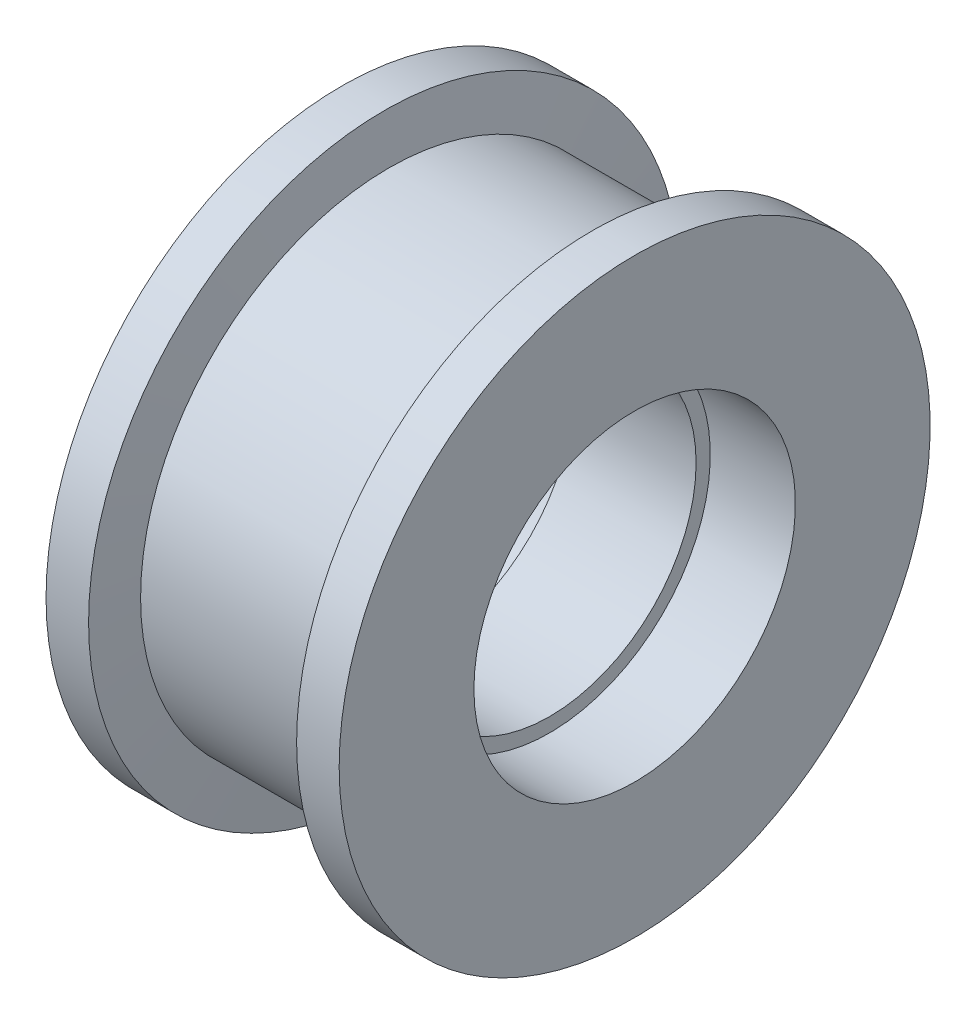
from build123d import *


with BuildPart() as part:
    # 草图2 → 旋转2 (revolve)
    with BuildSketch(Plane(origin=(0, 0, 0), x_dir=(1, 0, 0), z_dir=(0, 1, 0))):
        Polygon((-4202.915240979, -7473.983238222), (-4193.915240979, -7473.983238222), (-4192.915240979, -7463.983238222), (-4150.915240979, -7463.983238222), (-4149.915240979, -7473.983238222), (-4140.915240979, -7473.983238222), (-4140.915240979, -7445.483238222), (-4158.915240979, -7445.483238222), (-4158.915240979, -7442.483238222), (-4184.915240979, -7442.483238222), (-4184.915240979, -7445.483238222), (-4202.915240979, -7445.483238222), align=None)
    revolve(axis=Axis((-4235.178380328, 0, 7411.483238222), (1, 0, 0)))


solid = part.part
